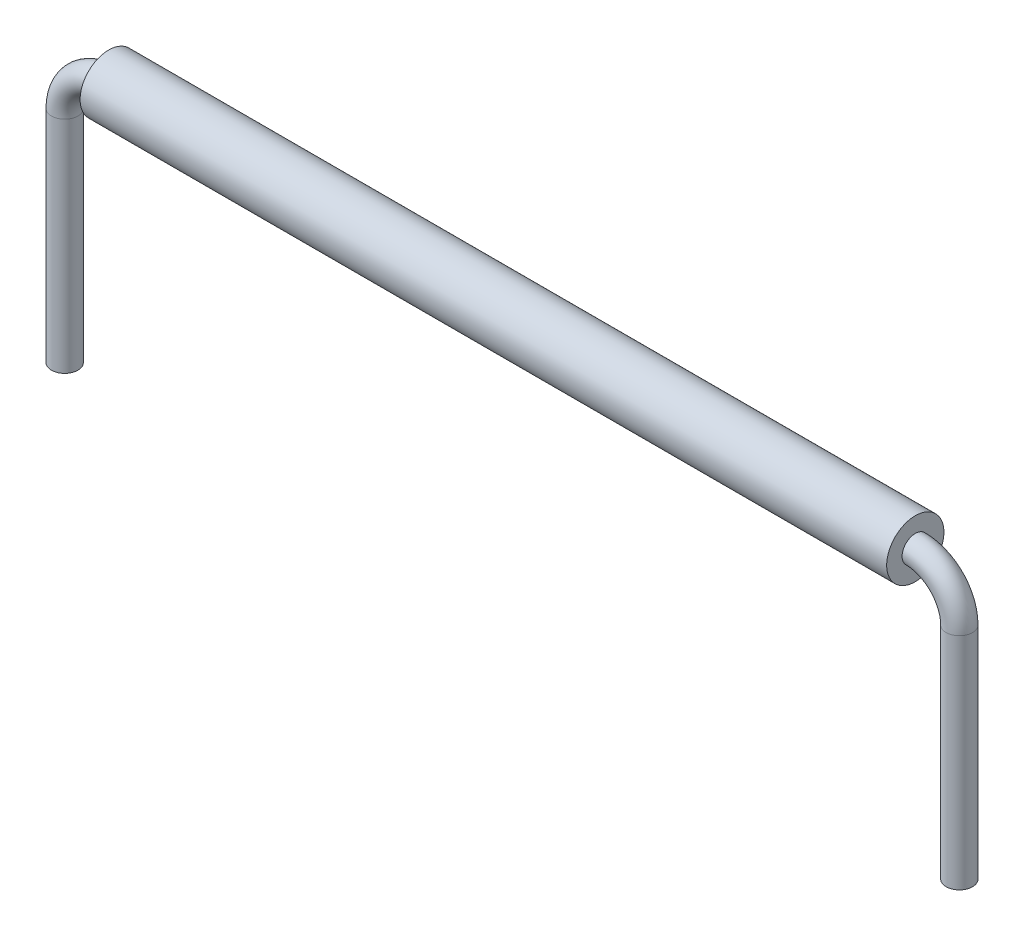
from build123d import *

# Parameters (mm, degrees)
SKETCH2_R                = 0.3
SKETCH3_R                = 0.65
SKETCH3_R_2              = 0.3
BOSS_EXTRUDE1_DEPTH      = 9.16
BOSS_EXTRUDE1_DEPTH_BACK = 9.16


with BuildPart() as part:
    # Sweep1: sweep along a path in Sketch1
    with BuildLine(Plane.XY) as sweep1_path:
        Line((-10.16, -6), (-10.16, -1))
        ThreePointArc((-10.16, -1), (-9.867106781, -0.292893219), (-9.16, 0))
        Line((-9.16, 0), (9.16, 0))
        ThreePointArc((9.16, 0), (9.867106781, -0.292893219), (10.16, -1))
        Line((10.16, -1), (10.16, -6))
    # Sketch2 → Sweep1 (sweep)
    with BuildSketch(Plane(origin=(0, 0, 0), x_dir=(0, 0, -1), z_dir=(1, 0, 0))):
        Circle(SKETCH2_R)
    sweep(path=sweep1_path.line)


with BuildPart() as body_2:
    # Sketch3 → Boss-Extrude1 (new body, two sides)
    with BuildSketch(Plane(origin=(0, 0, 0), x_dir=(0, 0, -1), z_dir=(1, 0, 0))) as boss_extrude1_sk:
        Circle(SKETCH3_R)
        Circle(SKETCH3_R_2, mode=Mode.SUBTRACT)
    extrude(amount=BOSS_EXTRUDE1_DEPTH)
    extrude(boss_extrude1_sk.sketch, amount=-BOSS_EXTRUDE1_DEPTH_BACK)


solid = Compound([part.part, body_2.part])
